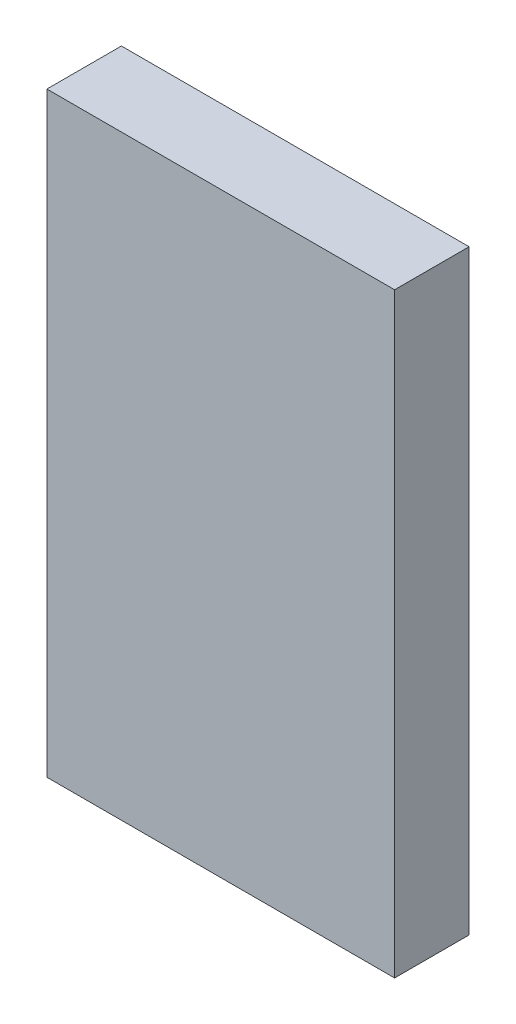
from build123d import *

# Parameters (mm, degrees)
SKETCH1_W           = 35.56
SKETCH1_H           = 60.96
BOSS_EXTRUDE1_DEPTH = 7.62


with BuildPart() as part:
    # Sketch1 → Boss-Extrude1 (new body)
    with BuildSketch(Plane.XY):
        with Locations((17.78, 30.48)):
            Rectangle(SKETCH1_W, SKETCH1_H)
    extrude(amount=BOSS_EXTRUDE1_DEPTH)


solid = part.part
